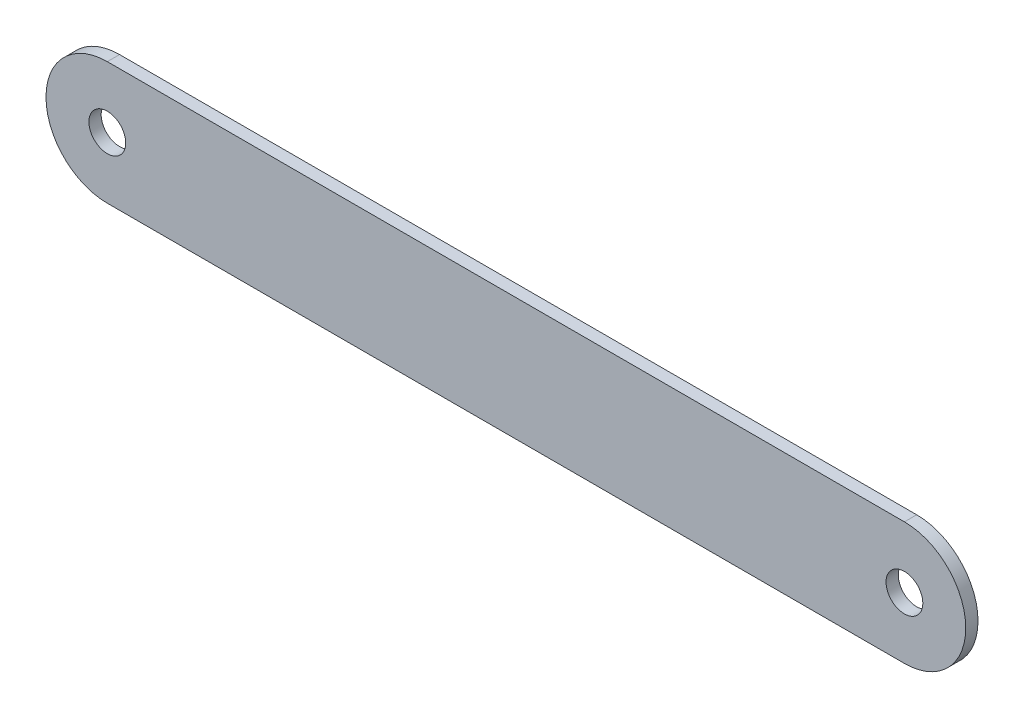
from build123d import *

# Parameters (mm, degrees)
IZIM1_R                     = 3
Y_KSEKLIK_EKSTR_ZYON1_DEPTH = 2


with BuildPart() as part:
    # Çizim1 → Yükseklik-Ekstrüzyon1 (new body)
    with BuildSketch(Plane.XY):
        with BuildLine():
            Line((-65, 9.999999679), (65, 9.999999679))
            ThreePointArc((65, 9.999999679), (74.999999679, 0), (65, -9.999999679))
            Line((65, -9.999999679), (-65, -9.999999679))
            ThreePointArc((-65, -9.999999679), (-74.999999679, 0), (-65, 9.999999679))
        make_face()
        with Locations((-65, 0)):
            Circle(IZIM1_R, mode=Mode.SUBTRACT)
        with Locations((65, 0)):
            Circle(IZIM1_R, mode=Mode.SUBTRACT)
    extrude(amount=Y_KSEKLIK_EKSTR_ZYON1_DEPTH)


solid = part.part
